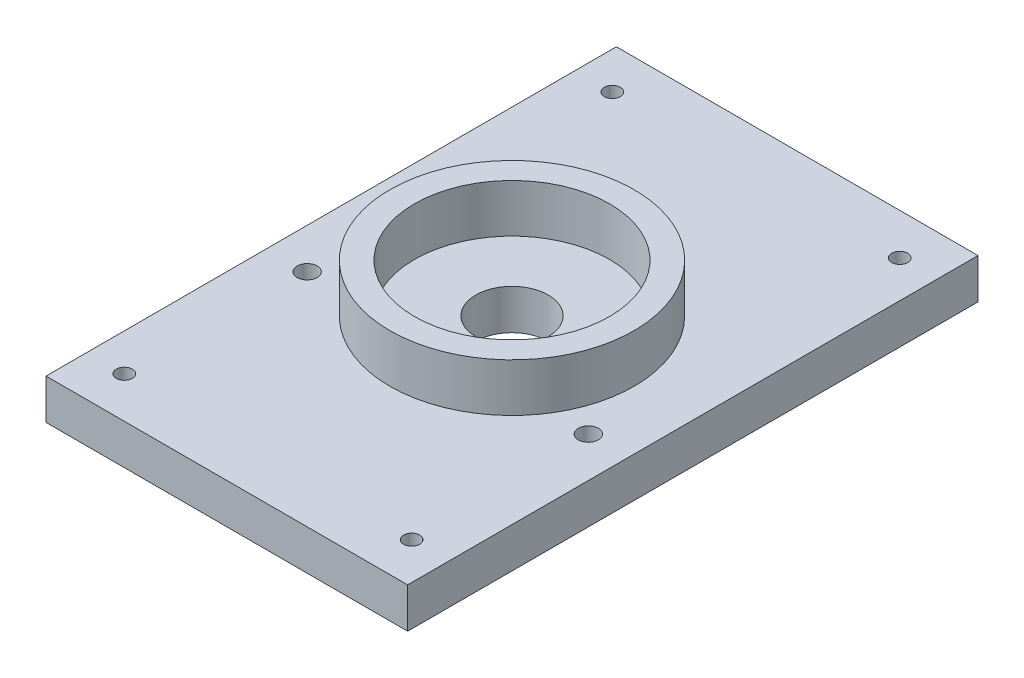
from build123d import *

# Parameters (mm, degrees)
SKETCH1_W           = 45.01572081
SKETCH1_H           = 71
SKETCH1_R           = 1.75
SKETCH1_R_2         = 4.5
BOSS_EXTRUDE1_DEPTH = 5
SKETCH2_R           = 15.2
SKETCH2_R_2         = 12.2
BOSS_EXTRUDE2_DEPTH = 6
SKETCH3_R           = 1.5
CUT_EXTRUDE1_DEPTH  = 60
SKETCH4_R           = 12.2
SKETCH4_R_2         = 12.15
BOSS_EXTRUDE3_DEPTH = 6
SKETCH5_R           = 1.5
SKETCH5_R_2         = 1
SKETCH5_R_3         = 1.75
SKETCH5_R_4         = 1.25
BOSS_EXTRUDE4_DEPTH = 5


with BuildPart() as part:
    # Sketch1 → Boss-Extrude1 (new body)
    with BuildSketch(Plane(origin=(0, 0, 0), x_dir=(1, 0, 0), z_dir=(0, 1, 0))):
        with Locations((0.136395343, 0.409186029)):
            Rectangle(SKETCH1_W, SKETCH1_H)
        with Locations((17.636395343, -7.590813971)):
            Circle(SKETCH1_R, mode=Mode.SUBTRACT)
        with Locations((0.136395343, 0.409186029)):
            Circle(SKETCH1_R_2, mode=Mode.SUBTRACT)
        with Locations((-17.363604657, -7.590813971)):
            Circle(SKETCH1_R, mode=Mode.SUBTRACT)
    extrude(amount=BOSS_EXTRUDE1_DEPTH)

    # Sketch2 → Boss-Extrude2 (add)
    with BuildSketch(Plane(origin=(0, 5, 0), x_dir=(1, 0, 0), z_dir=(0, 1, 0))):
        with Locations((0.136395343, 0.409186029)):
            Circle(SKETCH2_R)
        with Locations((0.136395343, 0.409186029)):
            Circle(SKETCH2_R_2, mode=Mode.SUBTRACT)
    extrude(amount=BOSS_EXTRUDE2_DEPTH)

    # Sketch3 → Cut-Extrude1 (cut)
    with BuildSketch(Plane.XZ):
        with Locations((18.022935404, 29.969493628)):
            Circle(SKETCH3_R)
        with Locations((-17.750144718, 29.969493628)):
            Circle(SKETCH3_R)
        with Locations((-17.750144718, -30.787865685)):
            Circle(SKETCH3_R)
        with Locations((18.022935404, -30.787865685)):
            Circle(SKETCH3_R)
    extrude(amount=-CUT_EXTRUDE1_DEPTH, mode=Mode.SUBTRACT)

    # Sketch4 → Boss-Extrude3 (add)
    with BuildSketch(Plane(origin=(0, 11, 0), x_dir=(1, 0, 0), z_dir=(0, 1, 0))):
        with Locations((0.136395343, 0.409186029)):
            Circle(SKETCH4_R)
        with Locations((0.136395343, 0.409186029)):
            Circle(SKETCH4_R_2, mode=Mode.SUBTRACT)
    extrude(amount=-BOSS_EXTRUDE3_DEPTH)

    # Sketch5 → Boss-Extrude4 (add)
    with BuildSketch(Plane(origin=(0, 5, 0), x_dir=(1, 0, 0), z_dir=(0, 1, 0))):
        with Locations((-17.750144718, -29.969493628)):
            Circle(SKETCH5_R)
        with Locations((-17.750144718, -29.969493628)):
            Circle(SKETCH5_R_2, mode=Mode.SUBTRACT)
        with Locations((18.022935404, -29.969493628)):
            Circle(SKETCH5_R)
        with Locations((18.022935404, -29.969493628)):
            Circle(SKETCH5_R_2, mode=Mode.SUBTRACT)
        with Locations((17.636395343, -7.590813971)):
            Circle(SKETCH5_R_3)
        with Locations((17.636395343, -7.590813971)):
            Circle(SKETCH5_R_4, mode=Mode.SUBTRACT)
        with Locations((-17.363604657, -7.590813971)):
            Circle(SKETCH5_R_3)
        with Locations((-17.363604657, -7.590813971)):
            Circle(SKETCH5_R_4, mode=Mode.SUBTRACT)
        with Locations((-17.750144718, 30.787865685)):
            Circle(SKETCH5_R)
        with Locations((-17.750144718, 30.787865685)):
            Circle(SKETCH5_R_2, mode=Mode.SUBTRACT)
        with Locations((18.022935404, 30.787865685)):
            Circle(SKETCH5_R)
        with Locations((18.022935404, 30.787865685)):
            Circle(SKETCH5_R_2, mode=Mode.SUBTRACT)
    extrude(amount=-BOSS_EXTRUDE4_DEPTH)


solid = part.part
